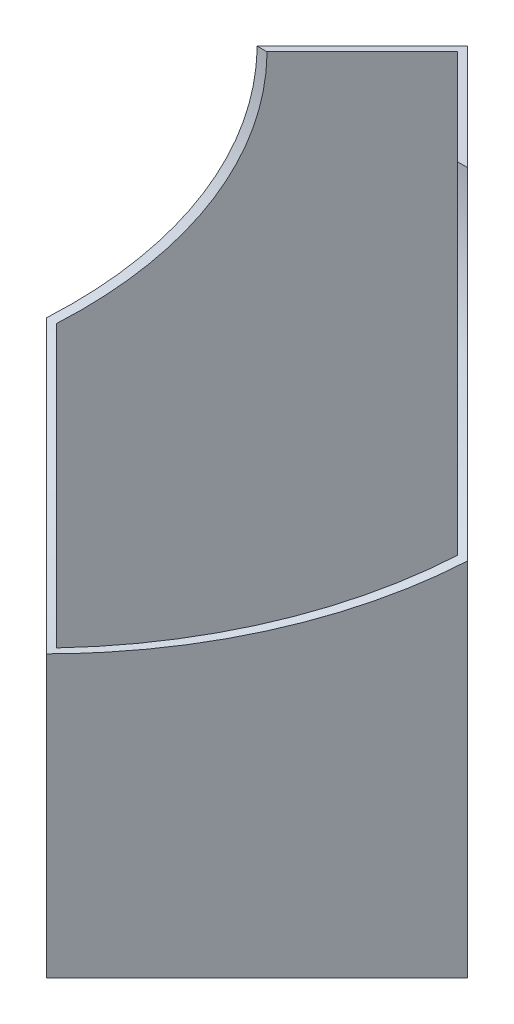
from build123d import *

# Parameters (mm, degrees)
EXTRUDE1_DEPTH     = 85
SHELL1_T           = -1
SKETCH3_R          = 45
CUT_EXTRUDE1_DEPTH = 30


with BuildPart() as part:
    # Sketch1 → Extrude1 (new body)
    with BuildSketch(Plane(origin=(0, 0, 0), x_dir=(1, 0, 0), z_dir=(0, 1, 0))):
        Polygon((0, 30), (30, 0), (0, -30), (-30, 0), align=None)
    extrude(amount=EXTRUDE1_DEPTH)

    # Shell1
    shell1_openings = [part.faces().sort_by_distance(p)[0] for p in [
        (0, 85, 0),
        (0, 0, 0),
    ]]
    offset(amount=SHELL1_T, openings=shell1_openings, kind=Kind.INTERSECTION)

    # Sketch3 → Cut-Extrude1 (cut, symmetric)
    with BuildSketch(Plane(origin=(0, 0, 0), x_dir=(0, 0, -1), z_dir=(1, 0, 0))):
        with Locations((-30, 85)):
            Circle(SKETCH3_R)
    extrude(amount=CUT_EXTRUDE1_DEPTH, both=True, mode=Mode.SUBTRACT)


solid = part.part
